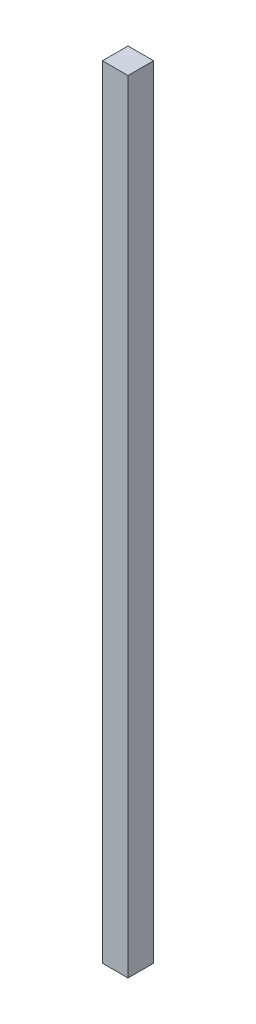
from build123d import *

# Parameters (mm, degrees)
SKETCH1_W           = 25.4
SKETCH1_H           = 25.4
BOSS_EXTRUDE1_DEPTH = 775.97


with BuildPart() as part:
    # Sketch1 → Boss-Extrude1 (new body)
    with BuildSketch(Plane(origin=(0, 0, 0), x_dir=(1, 0, 0), z_dir=(0, 1, 0))):
        Rectangle(SKETCH1_W, SKETCH1_H)
    extrude(amount=BOSS_EXTRUDE1_DEPTH)


solid = part.part
